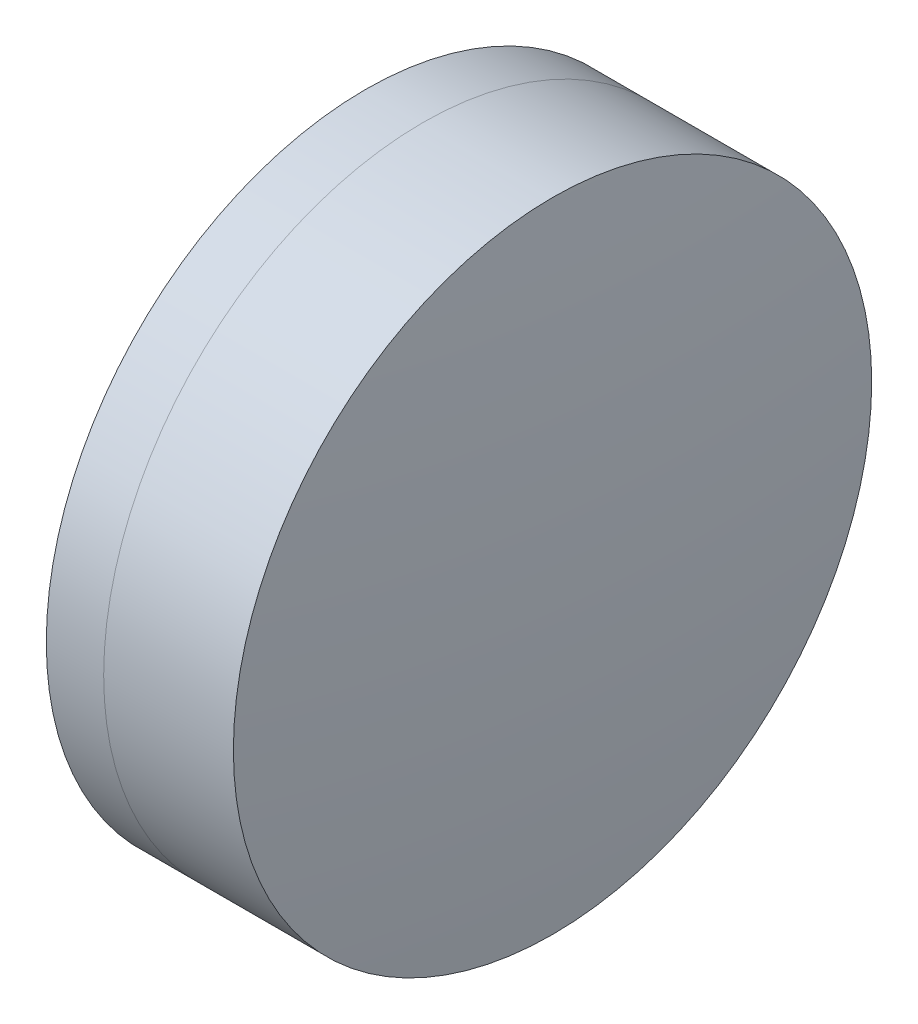
from build123d import *


with BuildPart() as part:
    # 草图1 one side → 旋转1 (revolve)
    with BuildSketch(Plane(origin=(0, 0, 0), x_dir=(1, 0, 0), z_dir=(0, 1, 0)), mode=Mode.PRIVATE) as revolve_1_sk:
        with BuildLine():
            ThreePointArc((297.916826095, 25.4), (292.841884632, 13.148007491), (291.110916607, 0))
            Line((291.110916607, 0), (311.110916607, 0))
            ThreePointArc((311.110916607, 0), (308.894934019, 13.41276888), (302.482505623, 25.4))
            Line((302.482505623, 25.4), (297.916826095, 25.4))
        make_face()
    revolve(revolve_1_sk.sketch.rotate(Axis((124.523309526, 0, 0), (1, 0, 0)), 180), axis=Axis((124.523309526, 0, 0), (1, 0, 0)))  # turned: the seam where the file's is


with BuildPart() as body_2:
    # 草图2 one side → 旋转3 (revolve)
    with BuildSketch(Plane(origin=(0, 0, 0), x_dir=(1, 0, 0), z_dir=(0, 1, 0)), mode=Mode.PRIVATE) as revolve_3_sk:
        with BuildLine():
            Line((312.805173846, 25.4), (302.482505623, 25.4))
            ThreePointArc((302.482505623, 25.4), (308.894934019, 13.41276888), (311.110916607, 0))
            Line((311.110916607, 0), (314.110916607, 0))
            ThreePointArc((314.110916607, 0), (313.784265533, 12.716770071), (312.805173846, 25.4))
        make_face()
    revolve(revolve_3_sk.sketch.rotate(Axis((-0.551919993, 0, 0), (1, 0, 0)), 180), axis=Axis((-0.551919993, 0, 0), (1, 0, 0)))  # turned: the seam where the file's is


solid = Compound([part.part, body_2.part])
